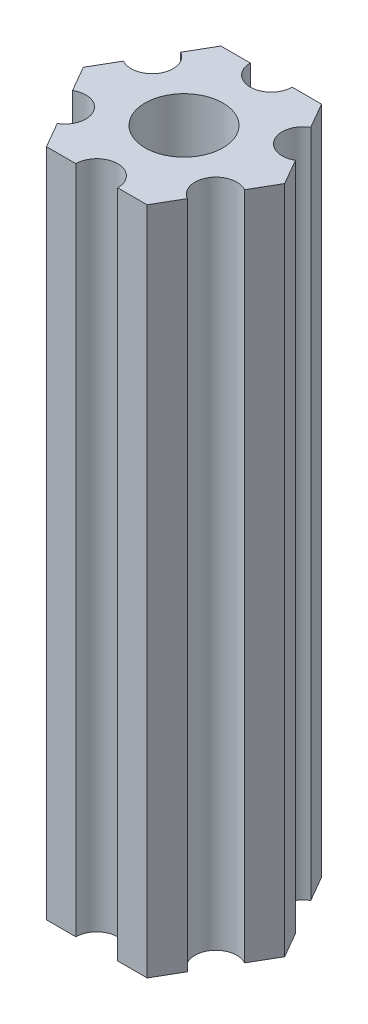
from build123d import *

# Parameters (mm, degrees)
ESBO_O1_R                = 2.79
RESSALTO_EXTRUS_O1_DEPTH = 48


with BuildPart() as part:
    # Esboço1 → Ressalto-extrusão1 (new body)
    with BuildSketch(Plane(origin=(0, 85, 0), x_dir=(1, 0, 0), z_dir=(0, 1, 0))):
        with BuildLine():
            Line((6.162658774, -1.825961894), (7.216878365, 0))
            Line((7.216878365, 0), (6.162658774, 1.825961894))
            ThreePointArc((6.162658774, 1.825961894), (4.113620668, 2.375), (4.662658774, 4.424038106))
            Line((4.662658774, 4.424038106), (3.608439182, 6.25))
            Line((3.608439182, 6.25), (1.5, 6.25))
            ThreePointArc((1.5, 6.25), (0, 4.75), (-1.5, 6.25))
            Line((-1.5, 6.25), (-3.608439182, 6.25))
            Line((-3.608439182, 6.25), (-4.662658774, 4.424038106))
            ThreePointArc((-4.662658774, 4.424038106), (-4.113620668, 2.375), (-6.162658774, 1.825961894))
            Line((-6.162658774, 1.825961894), (-7.216878365, 0))
            Line((-7.216878365, 0), (-6.162658774, -1.825961894))
            ThreePointArc((-6.162658774, -1.825961894), (-4.113620668, -2.375), (-4.662658774, -4.424038106))
            Line((-4.662658774, -4.424038106), (-3.608439182, -6.25))
            Line((-3.608439182, -6.25), (-1.5, -6.25))
            ThreePointArc((-1.5, -6.25), (0, -4.75), (1.5, -6.25))
            Line((1.5, -6.25), (3.608439182, -6.25))
            Line((3.608439182, -6.25), (4.662658774, -4.424038106))
            ThreePointArc((4.662658774, -4.424038106), (4.113620668, -2.375), (6.162658774, -1.825961894))
        make_face()
        Circle(ESBO_O1_R, mode=Mode.SUBTRACT)
    extrude(amount=-RESSALTO_EXTRUS_O1_DEPTH)


solid = part.part
